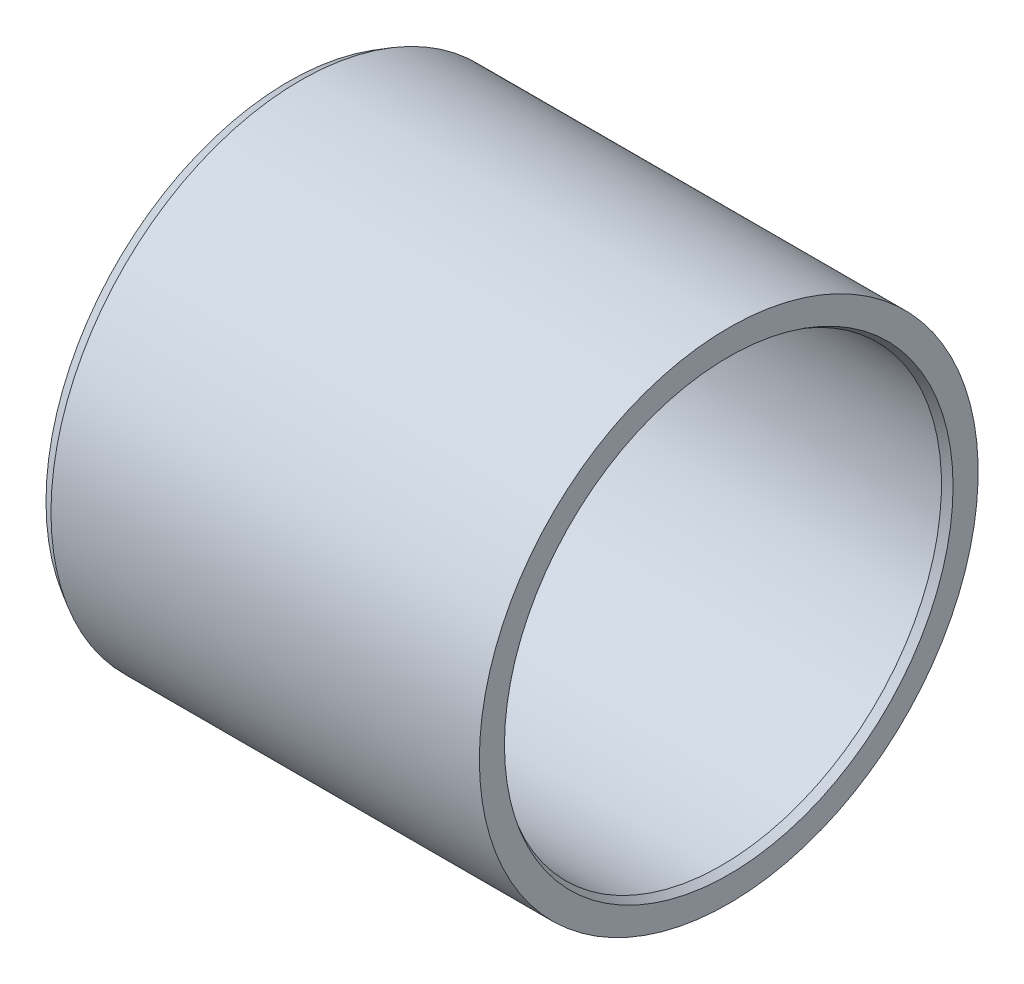
from build123d import *


with BuildPart() as part:
    # Skizze1 → Rotation1 (revolve)
    with BuildSketch(Plane(origin=(0, 0, 0), x_dir=(1, 0, 0), z_dir=(0, 1, 0))):
        Polygon((-14.2, 17), (15, 17), (15, 15.288675135), (14.5, 15), (-15, 15), (-15, 16.538119785), align=None)
    revolve(axis=Axis((-15, 0, 0), (1, 0, 0)))


solid = part.part
